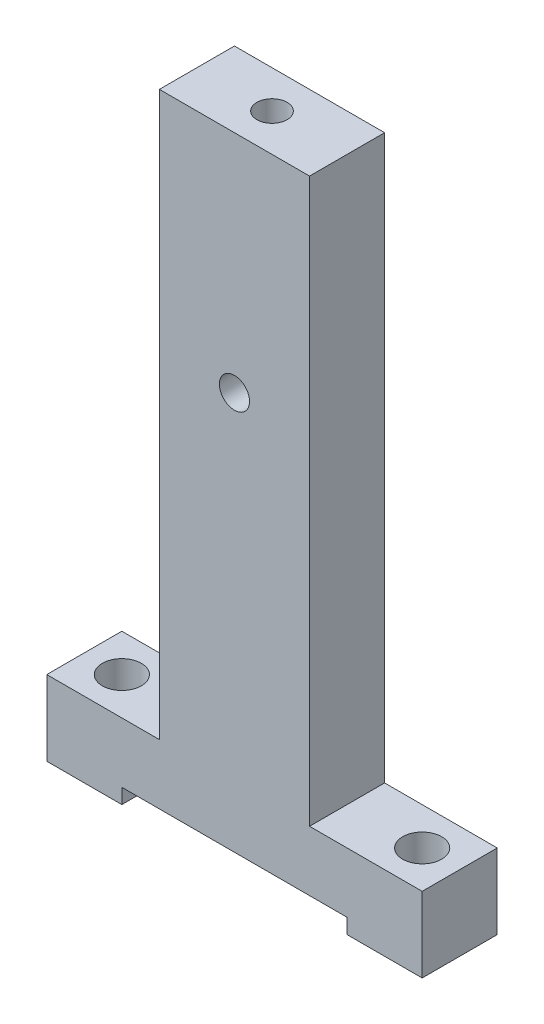
from build123d import *

# Parameters (mm, degrees)
SKETCH1_W                   = 63.5
SKETCH1_H                   = 12.7
BOSS_EXTRUDE1_DEPTH         = 53.975
CUT_EXTRUDE1_REACH          = 14.7
SKETCH2_W                   = 19.05
SKETCH2_H                   = 95.25
SKETCH3_R                   = 3.302
CUT_EXTRUDE2_DEPTH          = 13.7
F_1_4_20_TAPPED_HOLE1_D     = 5.1054
F_1_4_20_TAPPED_HOLE1_DEPTH = 19.05
F_1_4_20_TAPPED_HOLE1_TIP   = 1.533816902
SKETCH6_W                   = 38.1
SKETCH6_H                   = 2.54
CUT_EXTRUDE3_DEPTH          = 13.7
F_1_4_20_TAPPED_HOLE2_D     = 5.1054
F_1_4_20_TAPPED_HOLE2_DEPTH = 25.4
F_1_4_20_TAPPED_HOLE2_TIP   = 1.533816902


with BuildPart() as part:
    # Sketch1 → Boss-Extrude1 (new body, symmetric)
    with BuildSketch(Plane(origin=(0, 0, 0), x_dir=(1, 0, 0), z_dir=(0, 1, 0))):
        Rectangle(SKETCH1_W, SKETCH1_H)
    extrude(amount=BOSS_EXTRUDE1_DEPTH, both=True)

    # Sketch2 → Cut-Extrude1 (cut, up to next)
    with BuildSketch(Plane.XY.offset(6.35), mode=Mode.PRIVATE) as cut_extrude1_sk1:
        with Locations((-22.225, 6.35)):
            Rectangle(SKETCH2_W, SKETCH2_H)
    cut_extrude1_tool1 = extrude(cut_extrude1_sk1.sketch, amount=-CUT_EXTRUDE1_REACH, mode=Mode.PRIVATE) & part.part
    add(cut_extrude1_tool1.solids().sort_by_distance((-22.225, 6.35, 6.35))[0], mode=Mode.SUBTRACT)
    # Sketch2 → Cut-Extrude1 (cut, up to next)
    with BuildSketch(Plane.XY.offset(6.35), mode=Mode.PRIVATE) as cut_extrude1_sk2:
        with Locations((22.225, 6.35)):
            Rectangle(SKETCH2_W, SKETCH2_H)
    cut_extrude1_tool2 = extrude(cut_extrude1_sk2.sketch, amount=-CUT_EXTRUDE1_REACH, mode=Mode.PRIVATE) & part.part
    add(cut_extrude1_tool2.solids().sort_by_distance((22.225, 6.35, 6.35))[0], mode=Mode.SUBTRACT)

    # Sketch3 → Cut-Extrude2 (cut, through all)
    with BuildSketch(Plane(origin=(0, -41.275, 0), x_dir=(1, 0, 0), z_dir=(0, 1, 0))):
        with Locations((-25.4, 0)):
            Circle(SKETCH3_R)
        with Locations((25.4, 0)):
            Circle(SKETCH3_R)
    extrude(amount=-CUT_EXTRUDE2_DEPTH, mode=Mode.SUBTRACT)

    # 1/4-20 Tapped Hole1
    with Locations(Plane(origin=(0, 53.975, 0), x_dir=(1, 0, 0), z_dir=(0, 1, 0))):
        with Locations((0, 0)):
            Hole(F_1_4_20_TAPPED_HOLE1_D / 2, depth=F_1_4_20_TAPPED_HOLE1_DEPTH)
            with Locations((0, 0, -(F_1_4_20_TAPPED_HOLE1_DEPTH + F_1_4_20_TAPPED_HOLE1_TIP / 2))):  # 118° drill point
                Cone(0, F_1_4_20_TAPPED_HOLE1_D / 2, F_1_4_20_TAPPED_HOLE1_TIP, mode=Mode.SUBTRACT)

    # Sketch6 → Cut-Extrude3 (cut, through all)
    with BuildSketch(Plane.XY.offset(6.35)):
        with Locations((0, -52.705)):
            Rectangle(SKETCH6_W, SKETCH6_H)
    extrude(amount=-CUT_EXTRUDE3_DEPTH, mode=Mode.SUBTRACT)

    # 1/4-20 Tapped Hole2
    with Locations(Plane.XY.offset(6.35)):
        with Locations((0, 15.875)):
            Hole(F_1_4_20_TAPPED_HOLE2_D / 2, depth=F_1_4_20_TAPPED_HOLE2_DEPTH)
            with Locations((0, 0, -(F_1_4_20_TAPPED_HOLE2_DEPTH + F_1_4_20_TAPPED_HOLE2_TIP / 2))):  # 118° drill point
                Cone(0, F_1_4_20_TAPPED_HOLE2_D / 2, F_1_4_20_TAPPED_HOLE2_TIP, mode=Mode.SUBTRACT)


solid = part.part
